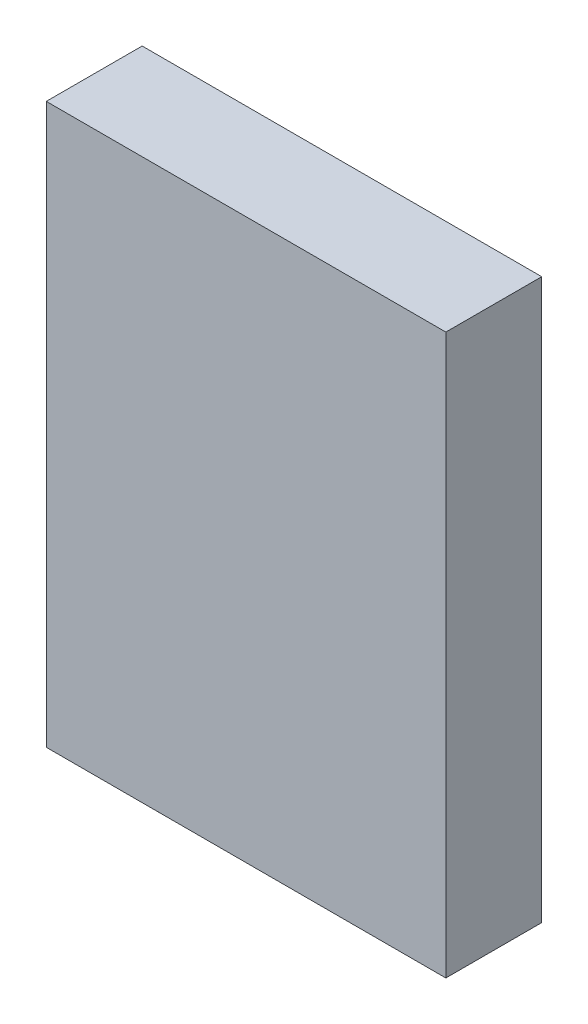
from build123d import *

# Parameters (mm, degrees)
SKETCH_1_W      = 12.5
SKETCH_1_H      = 17.5
EXTRUDE_1_DEPTH = 3


with BuildPart() as part:
    # 草图1 → 凸台-拉伸1 (new body)
    with BuildSketch(Plane.XY):
        with Locations((-0.101626016, -1.229674797)):
            Rectangle(SKETCH_1_W, SKETCH_1_H)
    extrude(amount=EXTRUDE_1_DEPTH)


solid = part.part
